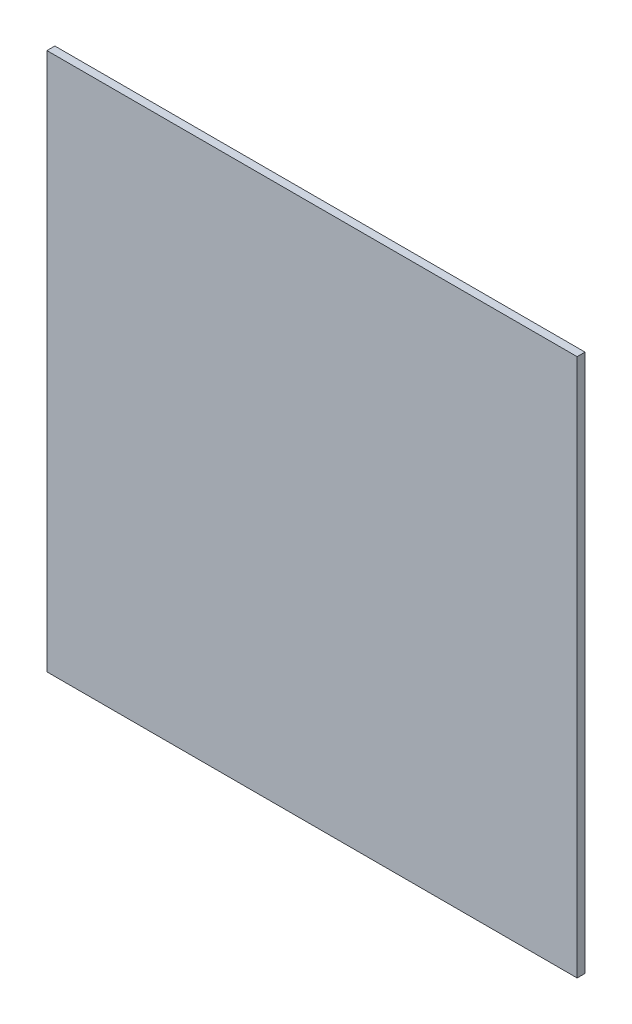
from build123d import *

# Parameters (mm, degrees)
SKETCH1_W      = 670
SKETCH1_H      = 680
EXTRUDE1_DEPTH = 10


with BuildPart() as part:
    # Sketch1 → Extrude1 (new body)
    with BuildSketch(Plane.XY):
        with Locations((335, 340)):
            Rectangle(SKETCH1_W, SKETCH1_H)
    extrude(amount=EXTRUDE1_DEPTH)


solid = part.part
